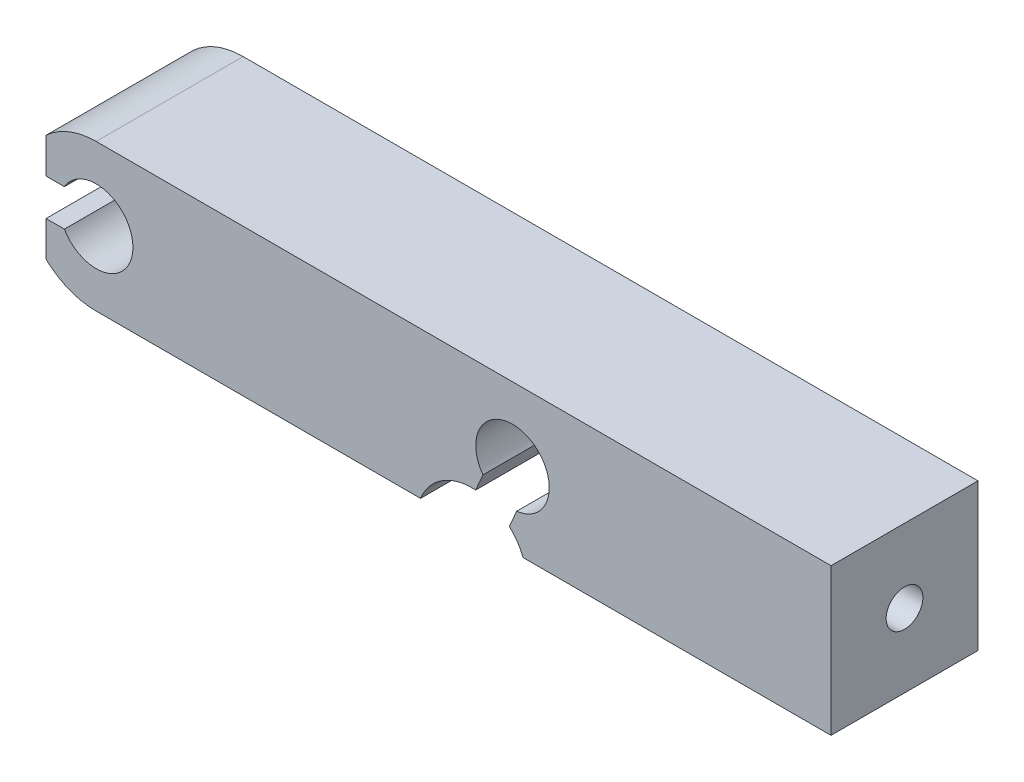
from build123d import *

# Parameters (mm, degrees)
EXTRUDE_1_DEPTH     = 4
SKETCH_4_R          = 0.5
CUT_EXTRUDE_1_DEPTH = 7
CUT_EXTRUDE_4_DEPTH = 3
CUT_EXTRUDE_5_DEPTH = 3
CUT_EXTRUDE_6_DEPTH = 3


with BuildPart() as part:
    # 草图3 → 凸台-拉伸1 (new body)
    with BuildSketch(Plane.XY):
        with BuildLine():
            Line((0, -2), (20, -2))
            Line((20, -2), (20, 2))
            Line((20, 2), (0, 2))
            ThreePointArc((0, 2), (-2, 0), (0, -2))
        make_face()
    extrude(amount=EXTRUDE_1_DEPTH)

    # 草图4 → 切除-拉伸1 (cut)
    with BuildSketch(Plane(origin=(20, 0, 0), x_dir=(0, 0, -1), z_dir=(1, 0, 0))):
        with Locations((-2, 0)):
            Circle(SKETCH_4_R)
    extrude(amount=-CUT_EXTRUDE_1_DEPTH, mode=Mode.SUBTRACT)

    # 草图5 → 切除-拉伸4 (cut)
    with BuildSketch(Plane.XY.offset(4)):
        with BuildLine():
            Line((-0.866025404, 0.5), (-1.366025404, 0.5))
            Line((-1.366025404, 0.5), (-1.366025404, 1.460812992))
            ThreePointArc((-1.366025404, 1.460812992), (-2, 0), (-1.366025404, -1.460812992))
            Line((-1.366025404, -1.460812992), (-1.366025404, -0.5))
            Line((-1.366025404, -0.5), (-0.866025404, -0.5))
            ThreePointArc((-0.866025404, -0.5), (1, 0), (-0.866025404, 0.5))
        make_face()
    extrude(amount=-CUT_EXTRUDE_4_DEPTH, mode=Mode.SUBTRACT)

    # 草图6 → 切除-拉伸5 (cut)
    with BuildSketch(Plane.XY.offset(1)):
        with BuildLine():
            Line((-1.366025404, 0.5), (-1.366025404, -0.5))
            Line((-1.366025404, -0.5), (-1.366025404, -1.460812992))
            ThreePointArc((-1.366025404, -1.460812992), (-2, 0), (-1.366025404, 1.460812992))
            Line((-1.366025404, 1.460812992), (-1.366025404, 0.5))
        make_face()
    extrude(amount=-CUT_EXTRUDE_5_DEPTH, mode=Mode.SUBTRACT)

    # 草图7 → 切除-拉伸6 (cut)
    with BuildSketch(Plane.XY.offset(4)):
        with BuildLine():
            Line((10.527261775, -0.595306745), (10.328163394, -1.053956758))
            ThreePointArc((10.328163394, -1.053956758), (9.423448211, -1.281600523), (8.828273079, -2))
            Line((8.828273079, -2), (9.917489301, -2))
            Line((9.917489301, -2), (11.007645162, -2))
            Line((11.007645162, -2), (11.619083211, -2))
            ThreePointArc((11.619083211, -2), (11.462926396, -1.705172003), (11.24546342, -1.45215352))
            Line((11.24546342, -1.45215352), (11.444561801, -0.993503507))
            ThreePointArc((11.444561801, -0.993503507), (11.728957062, 0.917300026), (10.527261775, -0.595306745))
        make_face()
    extrude(amount=-CUT_EXTRUDE_6_DEPTH, mode=Mode.SUBTRACT)


solid = part.part
